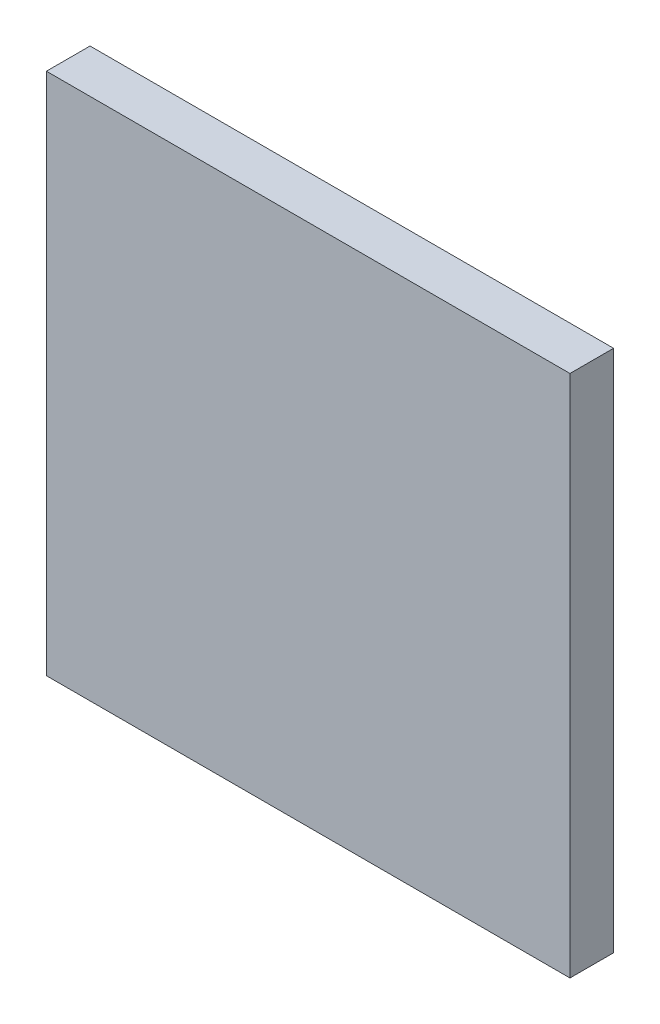
from build123d import *

# Parameters (mm, degrees)
SKETCH1_W           = 38.1
SKETCH1_H           = 38.1
BOSS_EXTRUDE1_DEPTH = 3.175


with BuildPart() as part:
    # Sketch1 → Boss-Extrude1 (new body)
    with BuildSketch(Plane.XY):
        Rectangle(SKETCH1_W, SKETCH1_H)
    extrude(amount=BOSS_EXTRUDE1_DEPTH)


solid = part.part
